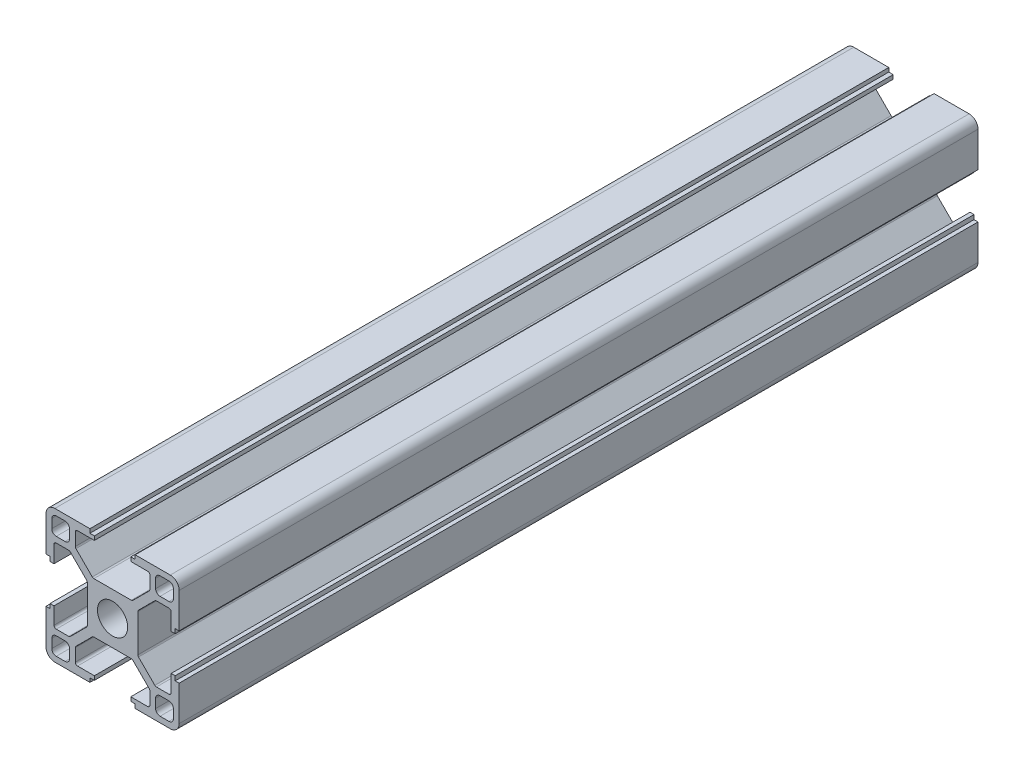
from build123d import *

# Parameters (mm, degrees)
SKETCH_1_W                       = 4
SKETCH_1_H                       = 4
EXTRUDE_1_DEPTH                  = 180
FILLET_1_R                       = 1
FILLET_2_R                       = 2
FILLET_3_R                       = 0.5
PATTERN_CIRCULAR_1_COUNT         = 4
FILLET_1_OF_PATTERN_CIRCULAR_1_R = 1
FILLET_2_OF_PATTERN_CIRCULAR_1_R = 2
FILLET_3_OF_PATTERN_CIRCULAR_1_R = 0.5
SKETCH_2_R                       = 3.4
CUT_EXTRUDE_1_DEPTH              = 181
SKETCH_3_R                       = 3.05
CUT_EXTRUDE_2_DEPTH              = 10


with BuildPart() as part:
    # 草图1 → 凸台-拉伸1 (new body)
    with BuildSketch(Plane.XY):
        Polygon((5.7, 0), (5.7, 4.427207794), (9.672792206, 8.4), (13.2, 8.4), (13.2, 4.1), (14.1, 4.1), (14.1, 5.1), (15, 5.1), (15, 15), (5.1, 15), (5.1, 14.1), (4.1, 14.1), (4.1, 13.2), (8.4, 13.2), (8.4, 9.672792206), (4.427207794, 5.7), (0, 5.7), (0, 0), align=None)
        with Locations((11.7, 11.7)):
            Rectangle(SKETCH_1_W, SKETCH_1_H, mode=Mode.SUBTRACT)
    extrude_1 = extrude(amount=EXTRUDE_1_DEPTH)

    # 圆角1
    fillet_1_edges = [part.edges().sort_by_distance(p)[0] for p in [
        (13.7, 9.7, 90),
        (13.7, 13.7, 90),
        (9.7, 13.7, 90),
        (9.7, 9.7, 90),
    ]]
    fillet(fillet_1_edges, radius=FILLET_1_R)

    # 圆角2
    fillet_2_edges = [part.edges().sort_by_distance(p)[0] for p in [
        (15, 15, 90),
    ]]
    fillet(fillet_2_edges, radius=FILLET_2_R)

    # 圆角3
    fillet_3_edges = [part.edges().sort_by_distance(p)[0] for p in [
        (4.427207794, 5.7, 90),
        (8.4, 9.672792206, 90),
        (8.4, 13.2, 90),
        (13.2, 8.4, 90),
        (9.672792206, 8.4, 90),
        (5.7, 4.427207794, 90),
    ]]
    fillet(fillet_3_edges, radius=FILLET_3_R)

    # 阵列(圆周)1: 凸台-拉伸1 ×4 about axis
    pattern_circular_1_axis = Axis((0, 0, 0), (0, 0, 1))
    for i in range(1, PATTERN_CIRCULAR_1_COUNT):
        add(extrude_1.rotate(pattern_circular_1_axis, i * 360 / PATTERN_CIRCULAR_1_COUNT))

    # 圆角1 of 阵列(圆周)1
    fillet_1_of_pattern_circular_1_edges = [part.edges().sort_by_distance(p)[0] for p in [
        (-9.7, 13.7, 90),
        (-13.7, 13.7, 90),
        (-13.7, 9.7, 90),
        (-9.7, 9.7, 90),
        (-13.7, -9.7, 90),
        (-13.7, -13.7, 90),
        (-9.7, -13.7, 90),
        (-9.7, -9.7, 90),
        (9.7, -13.7, 90),
        (13.7, -13.7, 90),
        (13.7, -9.7, 90),
        (9.7, -9.7, 90),
    ]]
    fillet(fillet_1_of_pattern_circular_1_edges, radius=FILLET_1_OF_PATTERN_CIRCULAR_1_R)

    # 圆角2 of 阵列(圆周)1
    fillet_2_of_pattern_circular_1_edges = [part.edges().sort_by_distance(p)[0] for p in [
        (-15, 15, 90),
        (-15, -15, 90),
        (15, -15, 90),
    ]]
    fillet(fillet_2_of_pattern_circular_1_edges, radius=FILLET_2_OF_PATTERN_CIRCULAR_1_R)

    # 圆角3 of 阵列(圆周)1
    fillet_3_of_pattern_circular_1_edges = [part.edges().sort_by_distance(p)[0] for p in [
        (-5.7, 4.427207794, 90),
        (-9.672792206, 8.4, 90),
        (-13.2, 8.4, 90),
        (-8.4, 13.2, 90),
        (-8.4, 9.672792206, 90),
        (-4.427207794, 5.7, 90),
        (-4.427207794, -5.7, 90),
        (-8.4, -9.672792206, 90),
        (-8.4, -13.2, 90),
        (-13.2, -8.4, 90),
        (-9.672792206, -8.4, 90),
        (-5.7, -4.427207794, 90),
        (5.7, -4.427207794, 90),
        (9.672792206, -8.4, 90),
        (13.2, -8.4, 90),
        (8.4, -13.2, 90),
        (8.4, -9.672792206, 90),
        (4.427207794, -5.7, 90),
    ]]
    fillet(fillet_3_of_pattern_circular_1_edges, radius=FILLET_3_OF_PATTERN_CIRCULAR_1_R)

    # 草图2 → 切除-拉伸1 (cut, through all)
    with BuildSketch(Plane.XY.offset(180)):
        Circle(SKETCH_2_R)
    extrude(amount=-CUT_EXTRUDE_1_DEPTH, mode=Mode.SUBTRACT)

    # 草图3 → 切除-拉伸2 (cut, symmetric)
    with BuildSketch(Plane(origin=(0, 0, 0), x_dir=(0, 0, -1), z_dir=(1, 0, 0))):
        with Locations((-8.5, 0)):
            Circle(SKETCH_3_R)
        with Locations((-71.5, 0)):
            Circle(SKETCH_3_R)
    extrude(amount=CUT_EXTRUDE_2_DEPTH, both=True, mode=Mode.SUBTRACT)


solid = part.part
